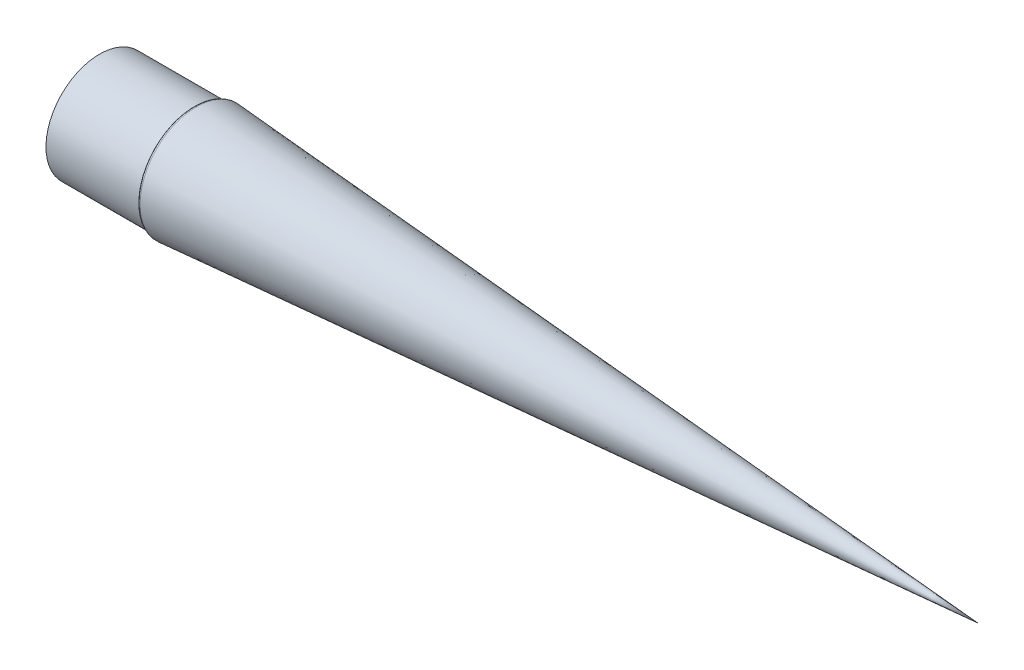
from build123d import *


with BuildPart() as part:
    # Sketch1 → Revolve1 (revolve)
    with BuildSketch(Plane.XY):
        with BuildLine():
            Line((-26.777640385, 14.5), (-1.377640385, 14.5))
            ThreePointArc((-1.377640385, 14.5), (-1.305458082, 14.529361179), (-1.274265968, 14.600771373))
            ThreePointArc((-1.274265968, 14.600771373), (-1.050186045, 15.089583285), (-0.541877208, 15.265))
            Line((-0.541877208, 15.265), (211.018122792, 0))
            Line((211.018122792, 0), (200.457781941, 0))
            Line((200.457781941, 0), (-0.569260312, 14.505))
            ThreePointArc((-0.569260312, 14.505), (-0.603115726, 14.493556272), (-0.618623339, 14.461359037))
            ThreePointArc((-0.618623339, 14.461359037), (-0.854079086, 13.949106575), (-1.377640385, 13.74))
            Line((-1.377640385, 13.74), (-26.777640385, 13.74))
            Line((-26.777640385, 13.74), (-26.777640385, 14.5))
        make_face()
    revolve(axis=Axis((0, 0, 0), (1, 0, 0)))


solid = part.part
